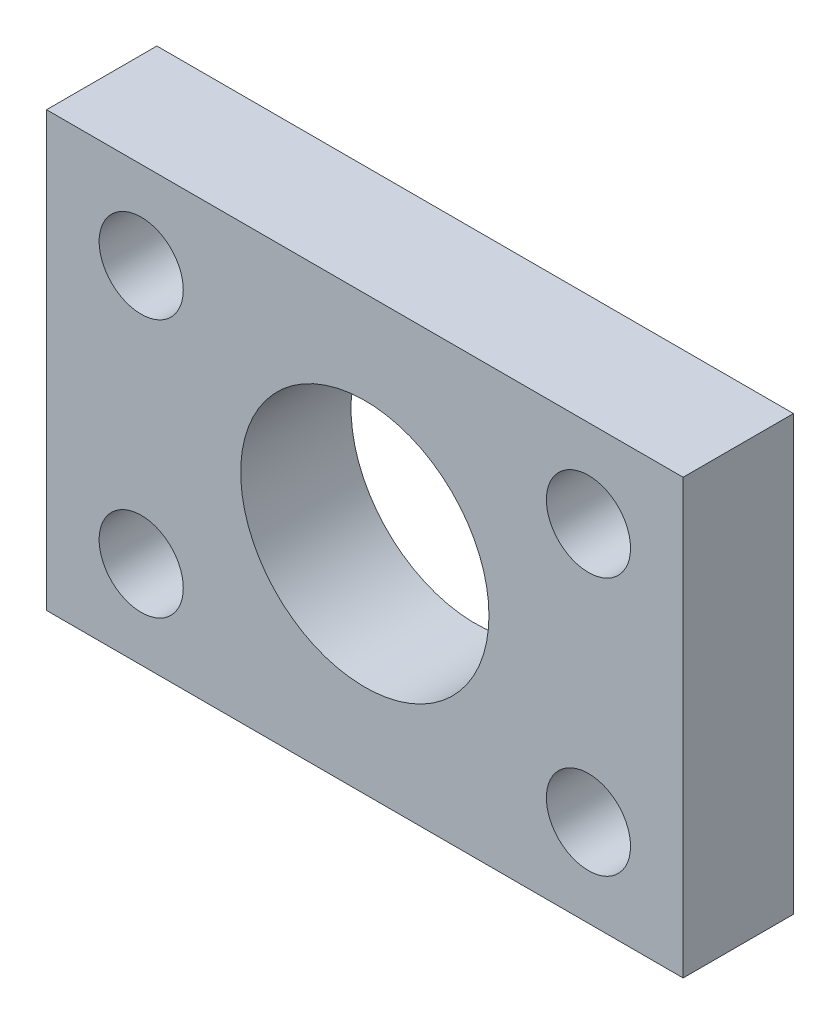
from build123d import *

# Parameters (mm, degrees)
SKETCH1_W           = 23.075946232
SKETCH1_H           = 15.72
SKETCH1_R           = 1.525
SKETCH1_R_2         = 4.5
BOSS_EXTRUDE2_DEPTH = 4


with BuildPart() as part:
    # Sketch1 → Boss-Extrude2 (new body)
    with BuildSketch(Plane.XY):
        Rectangle(SKETCH1_W, SKETCH1_H)
        with Locations((-8.105997779, -4.68)):
            Circle(SKETCH1_R, mode=Mode.SUBTRACT)
        with Locations((8.105997779, -4.68)):
            Circle(SKETCH1_R, mode=Mode.SUBTRACT)
        with Locations((8.105997779, 4.68)):
            Circle(SKETCH1_R, mode=Mode.SUBTRACT)
        with Locations((-8.105997779, 4.68)):
            Circle(SKETCH1_R, mode=Mode.SUBTRACT)
        Polygon((3.671947712, -6.36), (7.343895424, 0), (3.671947712, 6.36), (-3.671947712, 6.36), (-7.343895424, 0), (-3.671947712, -6.36), align=None, mode=Mode.SUBTRACT)
        Polygon((-3.671947712, -6.36), (3.671947712, -6.36), (7.343895424, 0), (3.671947712, 6.36), (-3.671947712, 6.36), (-7.343895424, 0), align=None)
        Circle(SKETCH1_R_2, mode=Mode.SUBTRACT)
    extrude(amount=BOSS_EXTRUDE2_DEPTH)


solid = part.part
